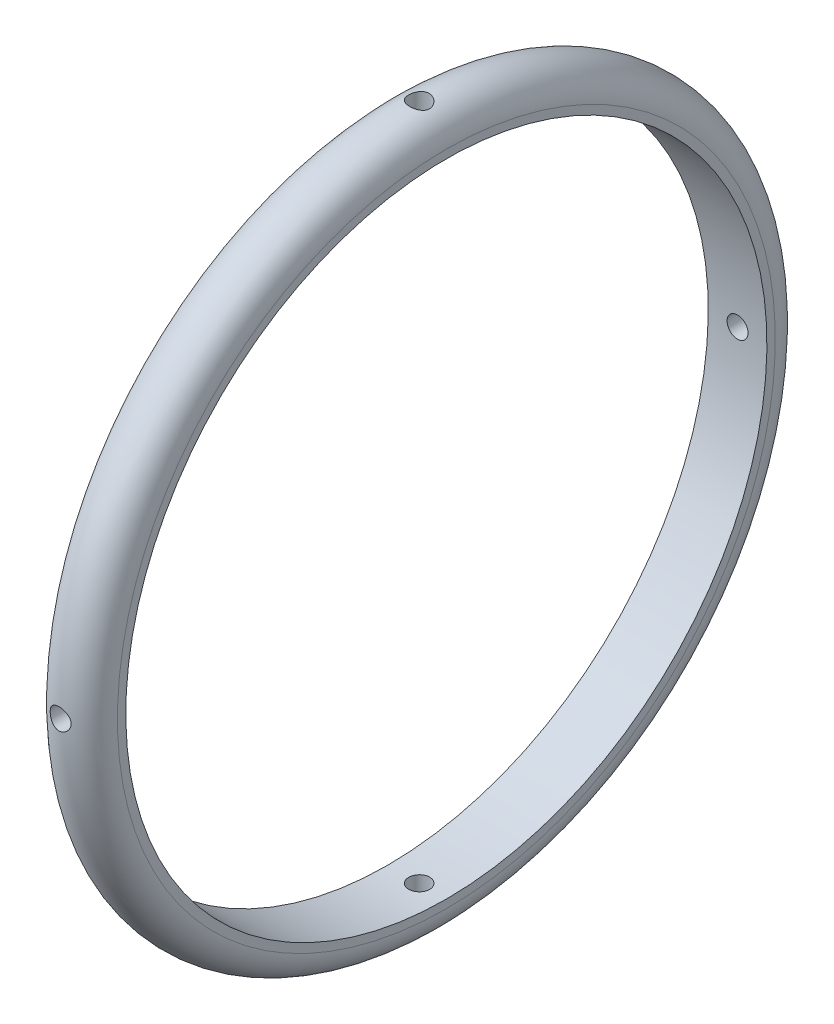
from build123d import *

# Parameters (mm, degrees)
CUT_EXTRUDE1_REACH             = 123.723
SKETCH1_3_R                    = 2.5
CUT_EXTRUDE1_DIRECTION_2_REACH = 123.723
CUT_EXTRUDE2_REACH             = 123.697
SKETCH2_R                      = 2.5
CUT_EXTRUDE2_DIRECTION_2_REACH = 123.697


with BuildPart() as part:
    # Sketch1 → Revolve1 (revolve)
    with BuildSketch(Plane.XY):
        with BuildLine():
            ThreePointArc((14, 78.5), (7, 85.5), (0, 78.5))
            Line((0, 78.5), (0, 76.5))
            Line((0, 76.5), (14, 76.5))
            Line((14, 76.5), (14, 78.5))
        make_face()
    revolve(axis=Axis((0, 0, 0), (1, 0, 0)))

    # Sketch1_3 → Cut-Extrude1 (cut, up to next)
    with BuildSketch(Plane.XY, mode=Mode.PRIVATE) as cut_extrude1_sk1:
        with Locations((7, 0)):
            Circle(SKETCH1_3_R)
    cut_extrude1_tool1 = extrude(cut_extrude1_sk1.sketch, amount=-CUT_EXTRUDE1_REACH, mode=Mode.PRIVATE) & part.part
    add(cut_extrude1_tool1.solids().sort_by_distance((7, 0, 0))[0], mode=Mode.SUBTRACT)

    # Sketch1_3 → Cut-Extrude1 direction 2 (cut, up to next)
    with BuildSketch(Plane.XY, mode=Mode.PRIVATE) as cut_extrude1_direction_2_sk1:
        with Locations((7, 0)):
            Circle(SKETCH1_3_R)
    cut_extrude1_direction_2_tool1 = extrude(cut_extrude1_direction_2_sk1.sketch, amount=CUT_EXTRUDE1_DIRECTION_2_REACH, mode=Mode.PRIVATE) & part.part
    add(cut_extrude1_direction_2_tool1.solids().sort_by_distance((7, 0, 0))[0], mode=Mode.SUBTRACT)

    # Sketch2 → Cut-Extrude2 (cut, up to next)
    with BuildSketch(Plane(origin=(0, 0, 0), x_dir=(1, 0, 0), z_dir=(0, 1, 0)), mode=Mode.PRIVATE) as cut_extrude2_sk1:
        with Locations((7.5, 0)):
            Circle(SKETCH2_R)
    cut_extrude2_tool1 = extrude(cut_extrude2_sk1.sketch, amount=-CUT_EXTRUDE2_REACH, mode=Mode.PRIVATE) & part.part
    add(cut_extrude2_tool1.solids().sort_by_distance((7.5, 0, 0))[0], mode=Mode.SUBTRACT)

    # Sketch2 → Cut-Extrude2 direction 2 (cut, up to next)
    with BuildSketch(Plane(origin=(0, 0, 0), x_dir=(1, 0, 0), z_dir=(0, 1, 0)), mode=Mode.PRIVATE) as cut_extrude2_direction_2_sk1:
        with Locations((7.5, 0)):
            Circle(SKETCH2_R)
    cut_extrude2_direction_2_tool1 = extrude(cut_extrude2_direction_2_sk1.sketch, amount=CUT_EXTRUDE2_DIRECTION_2_REACH, mode=Mode.PRIVATE) & part.part
    add(cut_extrude2_direction_2_tool1.solids().sort_by_distance((7.5, 0, 0))[0], mode=Mode.SUBTRACT)


solid = part.part
